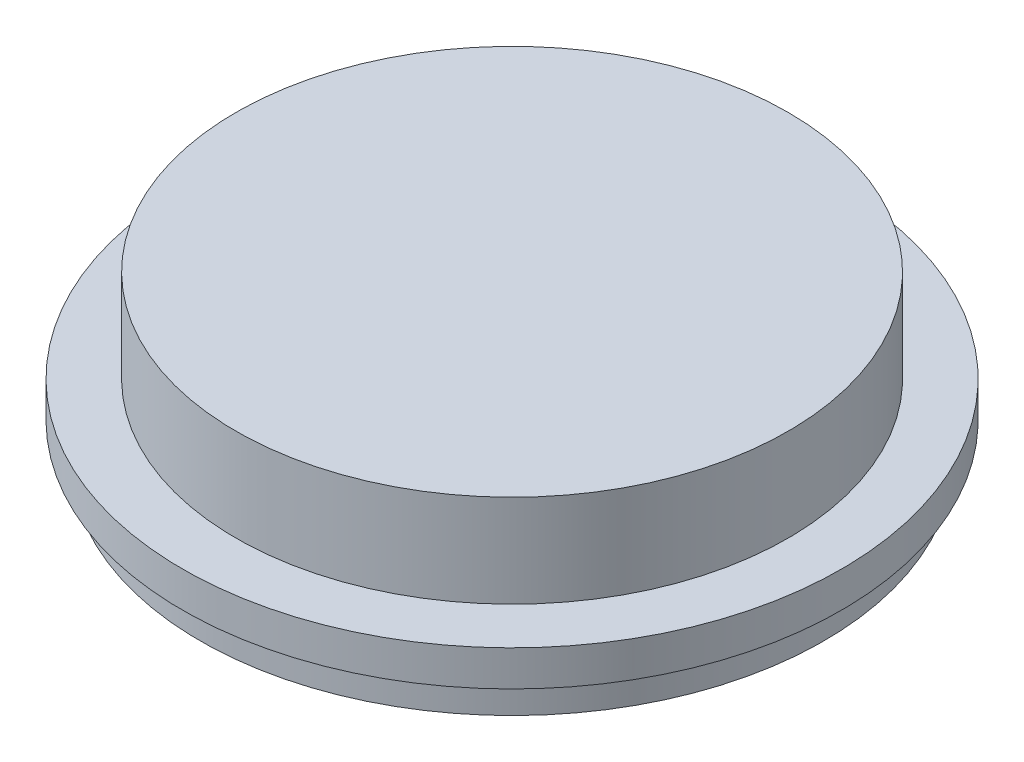
from build123d import *


with BuildPart() as part:
    # Sketch2 → Revolve1 (revolve)
    with BuildSketch(Plane.XY):
        Polygon((0, 0), (49.2125, 0), (49.2125, -16.51), (58.7375, -16.51), (58.7375, -22.86), (55.5625, -22.86), (55.5625, -29.21), (49.2125, -29.21), (49.2125, -22.86), (42.8625, -22.86), (42.8625, -6.35), (0, -6.35), align=None)
    revolve(axis=Axis((0, 0, 0), (0, 1, 0)))


solid = part.part
